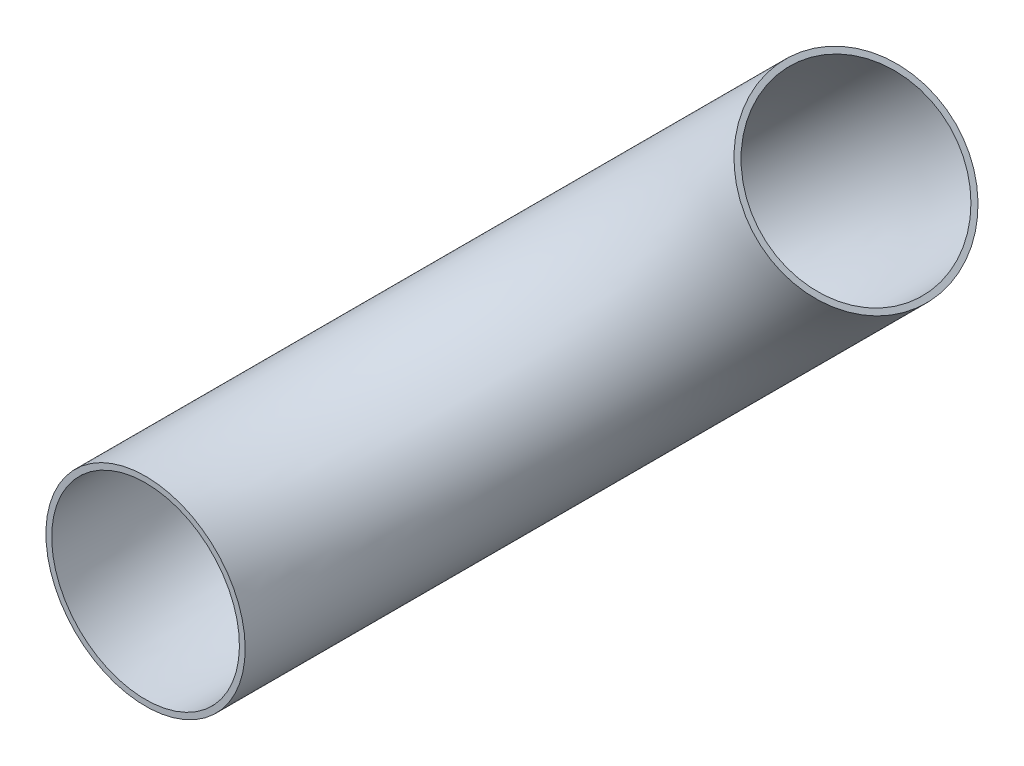
from build123d import *

# Parameters (mm, degrees)
PIPESKETCH_R   = 109.474
PIPESKETCH_R_2 = 103.124


with BuildPart() as part:
    # Sweep1: sweep along a curve in space
    with BuildLine() as sweep1_path:
        ThreePointArc((0, 0, 0), (94.689220358, 94.689220358, -323.289220358), (323.289220358, 323.289220358, -457.2))
    # PipeSketch → Sweep1 (sweep)
    with BuildSketch(Plane.XY):
        Circle(PIPESKETCH_R)
        Circle(PIPESKETCH_R_2, mode=Mode.SUBTRACT)
    sweep(path=sweep1_path.line)


solid = part.part
